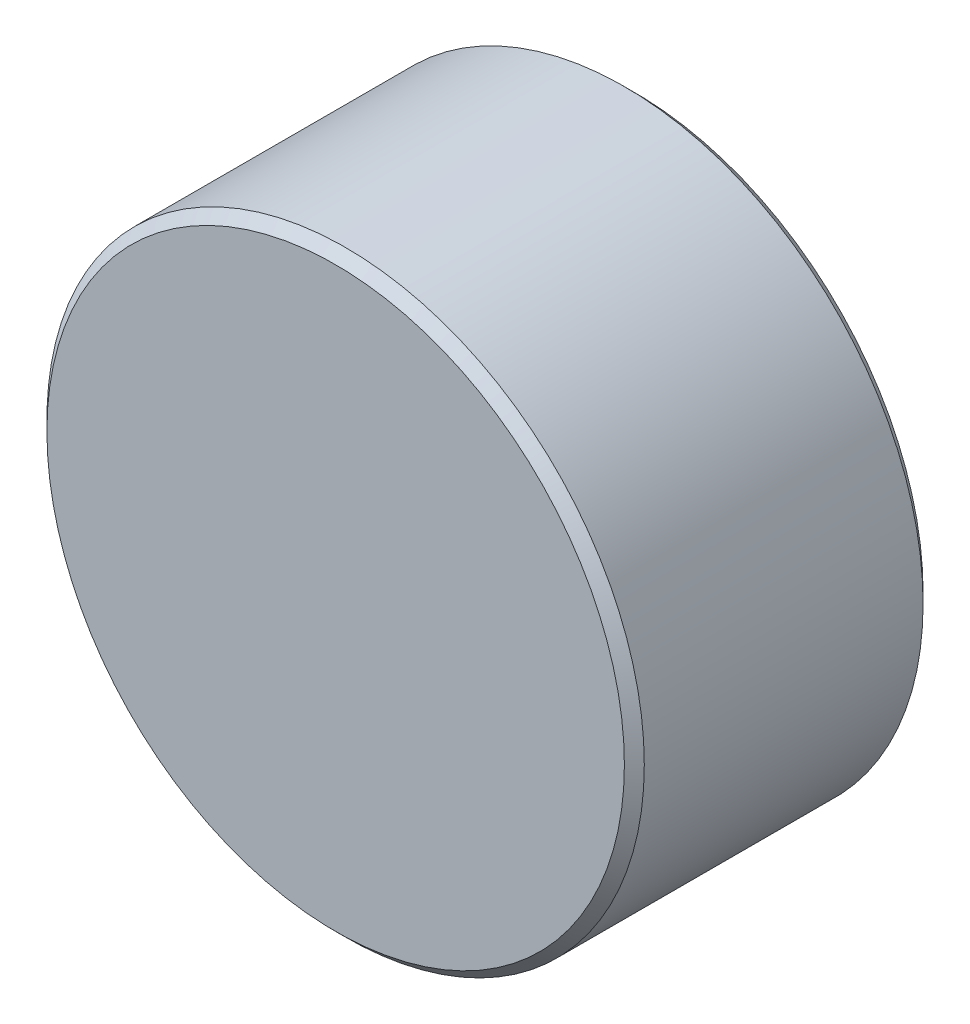
from build123d import *

# Parameters (mm, degrees)
SKETCH1_R           = 3
BOSS_EXTRUDE1_DEPTH = 3
CHAMFER1_SIZE       = 0.1


with BuildPart() as part:
    # Sketch1 → Boss-Extrude1 (new body)
    with BuildSketch(Plane.XY):
        Circle(SKETCH1_R)
    extrude(amount=BOSS_EXTRUDE1_DEPTH)

    # Chamfer1
    chamfer1_edges = [part.edges().sort_by_distance(p)[0] for p in [
        (-3, 0, 0),
        (-3, 0, 3),
    ]]
    chamfer(chamfer1_edges, length=CHAMFER1_SIZE)


solid = part.part
